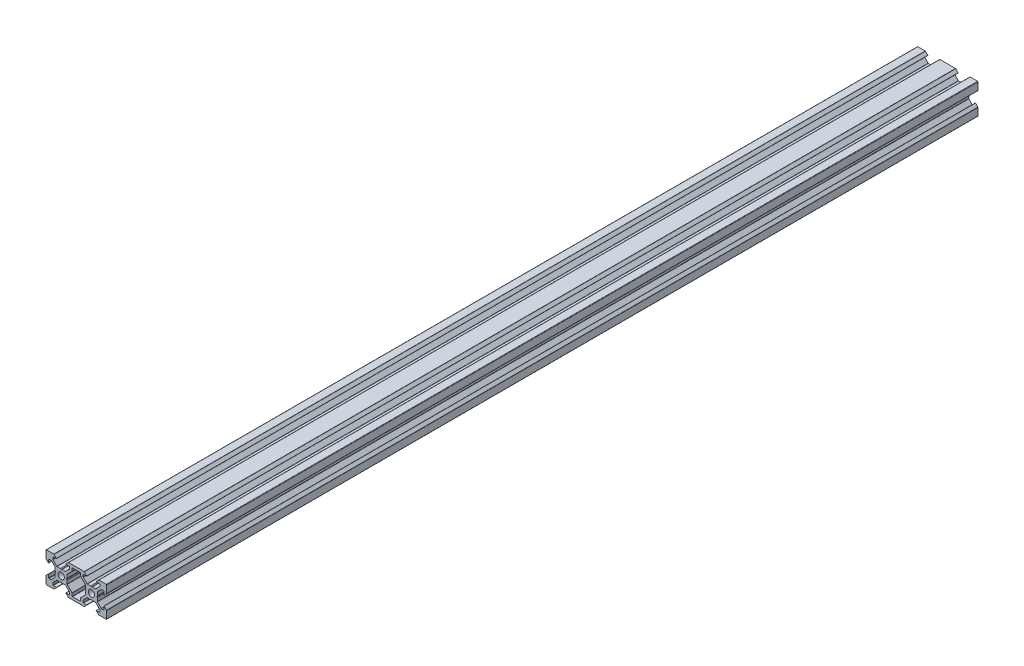
from build123d import *

# Parameters (mm, degrees)
BOSS_EXTRU_2_DEPTH = 575


with BuildPart() as part:
    # Esquisse1 → Boss.-Extru.2 (new body)
    with BuildSketch(Plane.XY):
        with BuildLine():
            Line((12.187742376, 2.734678815), (11.668127134, 3.034678815))
            Line((11.668127134, 3.034678815), (9.472006445, 3.034678815))
            ThreePointArc((9.472006445, 3.034678815), (9.357201415, 3.057514955), (9.25987441, 3.12254678))
            Line((9.25987441, 3.12254678), (6.776270514, 5.606150677))
            ThreePointArc((6.776270514, 5.606150677), (6.711238688, 5.703477682), (6.688402548, 5.818282711))
            Line((6.688402548, 5.818282711), (6.688402548, 7.034018643))
            ThreePointArc((6.688402548, 7.034018643), (6.776270514, 7.246150677), (6.988402548, 7.334018643))
            Line((6.988402548, 7.334018643), (8.987742376, 7.334018643))
            ThreePointArc((8.987742376, 7.334018643), (9.080130329, 7.3957503), (9.058453054, 7.504729321))
            Line((9.058453054, 7.504729321), (7.517031698, 9.046150677))
            ThreePointArc((7.517031698, 9.046150677), (7.419704693, 9.111182503), (7.304899664, 9.134018643))
            Line((7.304899664, 9.134018643), (2.187742376, 9.134018643))
            Line((2.187742376, 9.134018643), (-2.929414911, 9.134018643))
            ThreePointArc((-2.929414911, 9.134018643), (-3.044219941, 9.111182503), (-3.141546946, 9.046150677))
            Line((-3.141546946, 9.046150677), (-4.682968302, 7.504729321))
            ThreePointArc((-4.682968302, 7.504729321), (-4.704645577, 7.3957503), (-4.612257624, 7.334018643))
            Line((-4.612257624, 7.334018643), (-2.612917796, 7.334018643))
            ThreePointArc((-2.612917796, 7.334018643), (-2.400785761, 7.246150677), (-2.312917796, 7.034018643))
            Line((-2.312917796, 7.034018643), (-2.312917796, 5.818282711))
            ThreePointArc((-2.312917796, 5.818282711), (-2.335753936, 5.703477682), (-2.400785761, 5.606150677))
            Line((-2.400785761, 5.606150677), (-4.884389658, 3.12254678))
            ThreePointArc((-4.884389658, 3.12254678), (-4.981716663, 3.057514955), (-5.096521693, 3.034678815))
            Line((-5.096521693, 3.034678815), (-7.292642382, 3.034678815))
            Line((-7.292642382, 3.034678815), (-7.812257624, 2.734678815))
            Line((-7.812257624, 2.734678815), (-8.331872866, 3.034678815))
            Line((-8.331872866, 3.034678815), (-10.527993555, 3.034678815))
            ThreePointArc((-10.527993555, 3.034678815), (-10.642798585, 3.057514955), (-10.74012559, 3.12254678))
            Line((-10.74012559, 3.12254678), (-13.223729486, 5.606150677))
            ThreePointArc((-13.223729486, 5.606150677), (-13.288761312, 5.703477682), (-13.311597452, 5.818282711))
            Line((-13.311597452, 5.818282711), (-13.311597452, 7.034018643))
            ThreePointArc((-13.311597452, 7.034018643), (-13.223729486, 7.246150677), (-13.011597452, 7.334018643))
            Line((-13.011597452, 7.334018643), (-11.012257624, 7.334018643))
            ThreePointArc((-11.012257624, 7.334018643), (-10.919869671, 7.3957503), (-10.941546946, 7.504729321))
            Line((-10.941546946, 7.504729321), (-12.482968302, 9.046150677))
            ThreePointArc((-12.482968302, 9.046150677), (-12.580295307, 9.111182503), (-12.695100336, 9.134018643))
            Line((-12.695100336, 9.134018643), (-17.512257624, 9.134018643))
            ThreePointArc((-17.512257624, 9.134018643), (-17.724389658, 9.046150677), (-17.812257624, 8.834018643))
            Line((-17.812257624, 8.834018643), (-17.812257624, 4.016861355))
            ThreePointArc((-17.812257624, 4.016861355), (-17.789421484, 3.902056326), (-17.724389658, 3.804729321))
            Line((-17.724389658, 3.804729321), (-16.182968302, 2.263307965))
            ThreePointArc((-16.182968302, 2.263307965), (-16.073989281, 2.24163069), (-16.012257624, 2.334018643))
            Line((-16.012257624, 2.334018643), (-16.012257624, 4.333358471))
            ThreePointArc((-16.012257624, 4.333358471), (-15.924389658, 4.545490505), (-15.712257624, 4.633358471))
            Line((-15.712257624, 4.633358471), (-14.496521693, 4.633358471))
            ThreePointArc((-14.496521693, 4.633358471), (-14.381716663, 4.610522331), (-14.284389658, 4.545490505))
            Line((-14.284389658, 4.545490505), (-11.800785761, 2.061886608))
            ThreePointArc((-11.800785761, 2.061886608), (-11.735753936, 1.964559604), (-11.712917796, 1.849754574))
            Line((-11.712917796, 1.849754574), (-11.712917796, -0.346366115))
            Line((-11.712917796, -0.346366115), (-11.412917796, -0.865981357))
            Line((-11.412917796, -0.865981357), (-11.712917796, -1.385596599))
            Line((-11.712917796, -1.385596599), (-11.712917796, -3.581717289))
            ThreePointArc((-11.712917796, -3.581717289), (-11.735753936, -3.696522318), (-11.800785761, -3.793849323))
            Line((-11.800785761, -3.793849323), (-14.284389658, -6.27745322))
            ThreePointArc((-14.284389658, -6.27745322), (-14.381716663, -6.342485045), (-14.496521693, -6.365321185))
            Line((-14.496521693, -6.365321185), (-15.712257624, -6.365321185))
            ThreePointArc((-15.712257624, -6.365321185), (-15.924389658, -6.27745322), (-16.012257624, -6.065321185))
            Line((-16.012257624, -6.065321185), (-16.012257624, -4.065981357))
            ThreePointArc((-16.012257624, -4.065981357), (-16.073989281, -3.973593404), (-16.182968302, -3.995270679))
            Line((-16.182968302, -3.995270679), (-17.724389658, -5.536692035))
            ThreePointArc((-17.724389658, -5.536692035), (-17.789421484, -5.63401904), (-17.812257624, -5.74882407))
            Line((-17.812257624, -5.74882407), (-17.812257624, -10.565981357))
            ThreePointArc((-17.812257624, -10.565981357), (-17.724389658, -10.778113392), (-17.512257624, -10.865981357))
            Line((-17.512257624, -10.865981357), (-12.695100336, -10.865981357))
            ThreePointArc((-12.695100336, -10.865981357), (-12.580295307, -10.843145217), (-12.482968302, -10.778113392))
            Line((-12.482968302, -10.778113392), (-10.941546946, -9.236692035))
            ThreePointArc((-10.941546946, -9.236692035), (-10.919869671, -9.127713014), (-11.012257624, -9.065981357))
            Line((-11.012257624, -9.065981357), (-13.011597452, -9.065981357))
            ThreePointArc((-13.011597452, -9.065981357), (-13.223729486, -8.978113392), (-13.311597452, -8.765981357))
            Line((-13.311597452, -8.765981357), (-13.311597452, -7.550245426))
            ThreePointArc((-13.311597452, -7.550245426), (-13.288761312, -7.435440396), (-13.223729486, -7.338113392))
            Line((-13.223729486, -7.338113392), (-10.74012559, -4.854509495))
            ThreePointArc((-10.74012559, -4.854509495), (-10.642798585, -4.789477669), (-10.527993555, -4.766641529))
            Line((-10.527993555, -4.766641529), (-8.331872866, -4.766641529))
            Line((-8.331872866, -4.766641529), (-7.812257624, -4.466641529))
            Line((-7.812257624, -4.466641529), (-7.292642382, -4.766641529))
            Line((-7.292642382, -4.766641529), (-5.096521693, -4.766641529))
            ThreePointArc((-5.096521693, -4.766641529), (-4.981716663, -4.789477669), (-4.884389658, -4.854509495))
            Line((-4.884389658, -4.854509495), (-2.400785761, -7.338113392))
            ThreePointArc((-2.400785761, -7.338113392), (-2.335753936, -7.435440396), (-2.312917796, -7.550245426))
            Line((-2.312917796, -7.550245426), (-2.312917796, -8.765981357))
            ThreePointArc((-2.312917796, -8.765981357), (-2.400785761, -8.978113392), (-2.612917796, -9.065981357))
            Line((-2.612917796, -9.065981357), (-4.612257624, -9.065981357))
            ThreePointArc((-4.612257624, -9.065981357), (-4.704645577, -9.127713014), (-4.682968302, -9.236692035))
            Line((-4.682968302, -9.236692035), (-3.141546946, -10.778113392))
            ThreePointArc((-3.141546946, -10.778113392), (-3.044219941, -10.843145217), (-2.929414911, -10.865981357))
            Line((-2.929414911, -10.865981357), (2.187742376, -10.865981357))
            Line((2.187742376, -10.865981357), (7.304899664, -10.865981357))
            ThreePointArc((7.304899664, -10.865981357), (7.419704693, -10.843145217), (7.517031698, -10.778113392))
            Line((7.517031698, -10.778113392), (9.058453054, -9.236692035))
            ThreePointArc((9.058453054, -9.236692035), (9.080130329, -9.127713014), (8.987742376, -9.065981357))
            Line((8.987742376, -9.065981357), (6.988402548, -9.065981357))
            ThreePointArc((6.988402548, -9.065981357), (6.776270514, -8.978113392), (6.688402548, -8.765981357))
            Line((6.688402548, -8.765981357), (6.688402548, -7.550245426))
            ThreePointArc((6.688402548, -7.550245426), (6.711238688, -7.435440396), (6.776270514, -7.338113392))
            Line((6.776270514, -7.338113392), (9.25987441, -4.854509495))
            ThreePointArc((9.25987441, -4.854509495), (9.357201415, -4.789477669), (9.472006445, -4.766641529))
            Line((9.472006445, -4.766641529), (11.668127134, -4.766641529))
            Line((11.668127134, -4.766641529), (12.187742376, -4.466641529))
            Line((12.187742376, -4.466641529), (12.707357618, -4.766641529))
            Line((12.707357618, -4.766641529), (14.903478307, -4.766641529))
            ThreePointArc((14.903478307, -4.766641529), (15.018283337, -4.789477669), (15.115610342, -4.854509495))
            Line((15.115610342, -4.854509495), (17.599214239, -7.338113392))
            ThreePointArc((17.599214239, -7.338113392), (17.664246064, -7.435440396), (17.687082204, -7.550245426))
            Line((17.687082204, -7.550245426), (17.687082204, -8.765981357))
            ThreePointArc((17.687082204, -8.765981357), (17.599214239, -8.978113392), (17.387082204, -9.065981357))
            Line((17.387082204, -9.065981357), (15.387742376, -9.065981357))
            ThreePointArc((15.387742376, -9.065981357), (15.295354423, -9.127713014), (15.317031698, -9.236692035))
            Line((15.317031698, -9.236692035), (16.858453054, -10.778113392))
            ThreePointArc((16.858453054, -10.778113392), (16.955780059, -10.843145217), (17.070585089, -10.865981357))
            Line((17.070585089, -10.865981357), (21.887742376, -10.865981357))
            ThreePointArc((21.887742376, -10.865981357), (22.099874411, -10.778113392), (22.187742376, -10.565981357))
            Line((22.187742376, -10.565981357), (22.187742376, -5.74882407))
            ThreePointArc((22.187742376, -5.74882407), (22.164906236, -5.63401904), (22.09987441, -5.536692035))
            Line((22.09987441, -5.536692035), (20.558453054, -3.995270679))
            ThreePointArc((20.558453054, -3.995270679), (20.449474033, -3.973593404), (20.387742376, -4.065981357))
            Line((20.387742376, -4.065981357), (20.387742376, -6.065321185))
            ThreePointArc((20.387742376, -6.065321185), (20.29987441, -6.27745322), (20.087742376, -6.365321185))
            Line((20.087742376, -6.365321185), (18.872006445, -6.365321185))
            ThreePointArc((18.872006445, -6.365321185), (18.757201415, -6.342485045), (18.65987441, -6.27745322))
            Line((18.65987441, -6.27745322), (16.176270514, -3.793849323))
            ThreePointArc((16.176270514, -3.793849323), (16.111238688, -3.696522318), (16.088402548, -3.581717289))
            Line((16.088402548, -3.581717289), (16.088402548, -1.385596599))
            Line((16.088402548, -1.385596599), (15.788402548, -0.865981357))
            Line((15.788402548, -0.865981357), (16.088402548, -0.346366115))
            Line((16.088402548, -0.346366115), (16.088402548, 1.849754574))
            ThreePointArc((16.088402548, 1.849754574), (16.111238688, 1.964559604), (16.176270514, 2.061886608))
            Line((16.176270514, 2.061886608), (18.659874411, 4.545490505))
            ThreePointArc((18.659874411, 4.545490505), (18.757201415, 4.610522331), (18.872006445, 4.633358471))
            Line((18.872006445, 4.633358471), (20.087742376, 4.633358471))
            ThreePointArc((20.087742376, 4.633358471), (20.299874411, 4.545490505), (20.387742376, 4.333358471))
            Line((20.387742376, 4.333358471), (20.387742376, 2.334018643))
            ThreePointArc((20.387742376, 2.334018643), (20.449474033, 2.24163069), (20.558453054, 2.263307965))
            Line((20.558453054, 2.263307965), (22.099874411, 3.804729321))
            ThreePointArc((22.099874411, 3.804729321), (22.164906236, 3.902056326), (22.187742376, 4.016861355))
            Line((22.187742376, 4.016861355), (22.187742376, 8.834018643))
            ThreePointArc((22.187742376, 8.834018643), (22.099874411, 9.046150677), (21.887742376, 9.134018643))
            Line((21.887742376, 9.134018643), (17.070585089, 9.134018643))
            ThreePointArc((17.070585089, 9.134018643), (16.955780059, 9.111182503), (16.858453054, 9.046150677))
            Line((16.858453054, 9.046150677), (15.317031698, 7.504729321))
            ThreePointArc((15.317031698, 7.504729321), (15.295354423, 7.3957503), (15.387742376, 7.334018643))
            Line((15.387742376, 7.334018643), (17.387082204, 7.334018643))
            ThreePointArc((17.387082204, 7.334018643), (17.599214239, 7.246150677), (17.687082204, 7.034018643))
            Line((17.687082204, 7.034018643), (17.687082204, 5.818282711))
            ThreePointArc((17.687082204, 5.818282711), (17.664246064, 5.703477682), (17.599214239, 5.606150677))
            Line((17.599214239, 5.606150677), (15.115610342, 3.12254678))
            ThreePointArc((15.115610342, 3.12254678), (15.018283337, 3.057514955), (14.903478307, 3.034678815))
            Line((14.903478307, 3.034678815), (12.707357618, 3.034678815))
            Line((12.707357618, 3.034678815), (12.187742376, 2.734678815))
        make_face()
        with BuildLine():
            Line((4.927082204, -8.765981357), (4.927082204, -7.190245426))
            ThreePointArc((4.927082204, -7.190245426), (4.949918345, -7.075440396), (5.01495017, -6.978113392))
            Line((5.01495017, -6.978113392), (8.199214239, -3.793849323))
            ThreePointArc((8.199214239, -3.793849323), (8.264246064, -3.696522318), (8.287082204, -3.581717289))
            Line((8.287082204, -3.581717289), (8.287082204, -1.385596599))
            Line((8.287082204, -1.385596599), (8.587082204, -0.865981357))
            Line((8.587082204, -0.865981357), (8.287082204, -0.346366115))
            Line((8.287082204, -0.346366115), (8.287082204, 1.849754574))
            ThreePointArc((8.287082204, 1.849754574), (8.264246064, 1.964559604), (8.199214239, 2.061886608))
            Line((8.199214239, 2.061886608), (5.01495017, 5.246150677))
            ThreePointArc((5.01495017, 5.246150677), (4.949918345, 5.343477682), (4.927082204, 5.458282711))
            Line((4.927082204, 5.458282711), (4.927082204, 7.034018643))
            ThreePointArc((4.927082204, 7.034018643), (4.839214239, 7.246150677), (4.627082204, 7.334018643))
            Line((4.627082204, 7.334018643), (2.187742376, 7.334018643))
            Line((2.187742376, 7.334018643), (-0.251597452, 7.334018643))
            ThreePointArc((-0.251597452, 7.334018643), (-0.463729486, 7.246150677), (-0.551597452, 7.034018643))
            Line((-0.551597452, 7.034018643), (-0.551597452, 5.458282711))
            ThreePointArc((-0.551597452, 5.458282711), (-0.574433592, 5.343477682), (-0.639465418, 5.246150677))
            Line((-0.639465418, 5.246150677), (-3.823729486, 2.061886608))
            ThreePointArc((-3.823729486, 2.061886608), (-3.888761312, 1.964559604), (-3.911597452, 1.849754574))
            Line((-3.911597452, 1.849754574), (-3.911597452, -0.346366115))
            Line((-3.911597452, -0.346366115), (-4.211597452, -0.865981357))
            Line((-4.211597452, -0.865981357), (-3.911597452, -1.385596599))
            Line((-3.911597452, -1.385596599), (-3.911597452, -3.581717289))
            ThreePointArc((-3.911597452, -3.581717289), (-3.888761312, -3.696522318), (-3.823729486, -3.793849323))
            Line((-3.823729486, -3.793849323), (-0.639465418, -6.978113392))
            ThreePointArc((-0.639465418, -6.978113392), (-0.574433592, -7.075440396), (-0.551597452, -7.190245426))
            Line((-0.551597452, -7.190245426), (-0.551597452, -8.765981357))
            ThreePointArc((-0.551597452, -8.765981357), (-0.463729486, -8.978113392), (-0.251597452, -9.065981357))
            Line((-0.251597452, -9.065981357), (2.187742376, -9.065981357))
            Line((2.187742376, -9.065981357), (4.627082204, -9.065981357))
            ThreePointArc((4.627082204, -9.065981357), (4.839214239, -8.978113392), (4.927082204, -8.765981357))
        make_face(mode=Mode.SUBTRACT)
        with BuildLine():
            ThreePointArc((-7.812257624, 1.234018643), (-9.297181864, 0.618942883), (-9.912257624, -0.865981357))
            ThreePointArc((-9.912257624, -0.865981357), (-9.297181864, -2.350905598), (-7.812257624, -2.965981357))
            ThreePointArc((-7.812257624, -2.965981357), (-6.327333383, -2.350905598), (-5.712257624, -0.865981357))
            ThreePointArc((-5.712257624, -0.865981357), (-6.327333383, 0.618942883), (-7.812257624, 1.234018643))
        make_face(mode=Mode.SUBTRACT)
        with BuildLine():
            ThreePointArc((12.187742376, 1.234018643), (10.702818136, 0.618942883), (10.087742376, -0.865981357))
            ThreePointArc((10.087742376, -0.865981357), (10.702818136, -2.350905598), (12.187742376, -2.965981357))
            ThreePointArc((12.187742376, -2.965981357), (13.672666617, -2.350905598), (14.287742376, -0.865981357))
            ThreePointArc((14.287742376, -0.865981357), (13.672666617, 0.618942883), (12.187742376, 1.234018643))
        make_face(mode=Mode.SUBTRACT)
    extrude(amount=BOSS_EXTRU_2_DEPTH)


solid = part.part
